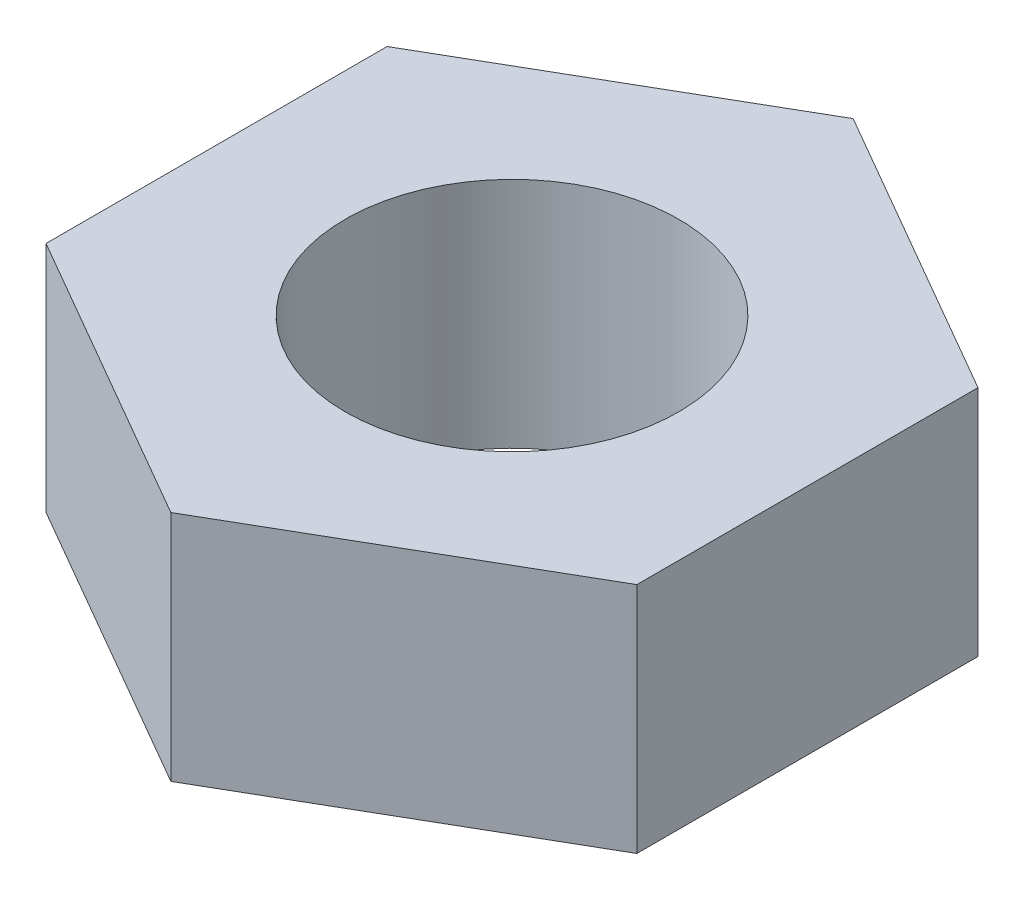
from build123d import *

# Parameters (mm, degrees)
BOSS_EXTRUDE1_DEPTH = 3.35
CUT_EXTRUDE1_REACH  = 5.35
SKETCH2_R           = 2.4


with BuildPart() as part:
    # Sketch1 → Boss-Extrude1 (new body)
    with BuildSketch(Plane(origin=(0, 0, 0), x_dir=(1, 0, 0), z_dir=(0, 1, 0))):
        Polygon((0, 4.907477288), (-4.25, 2.453738644), (-4.25, -2.453738644), (0, -4.907477288), (4.25, -2.453738644), (4.25, 2.453738644), align=None)
    extrude(amount=BOSS_EXTRUDE1_DEPTH)

    # Sketch2 → Cut-Extrude1 (cut, up to next)
    with BuildSketch(Plane(origin=(0, 3.35, 0), x_dir=(1, 0, 0), z_dir=(0, 1, 0)), mode=Mode.PRIVATE) as cut_extrude1_sk1:
        Circle(SKETCH2_R)
    cut_extrude1_tool1 = extrude(cut_extrude1_sk1.sketch, amount=-CUT_EXTRUDE1_REACH, mode=Mode.PRIVATE) & part.part
    add(cut_extrude1_tool1.solids().sort_by_distance((0, 3.35, 0))[0], mode=Mode.SUBTRACT)


solid = part.part
